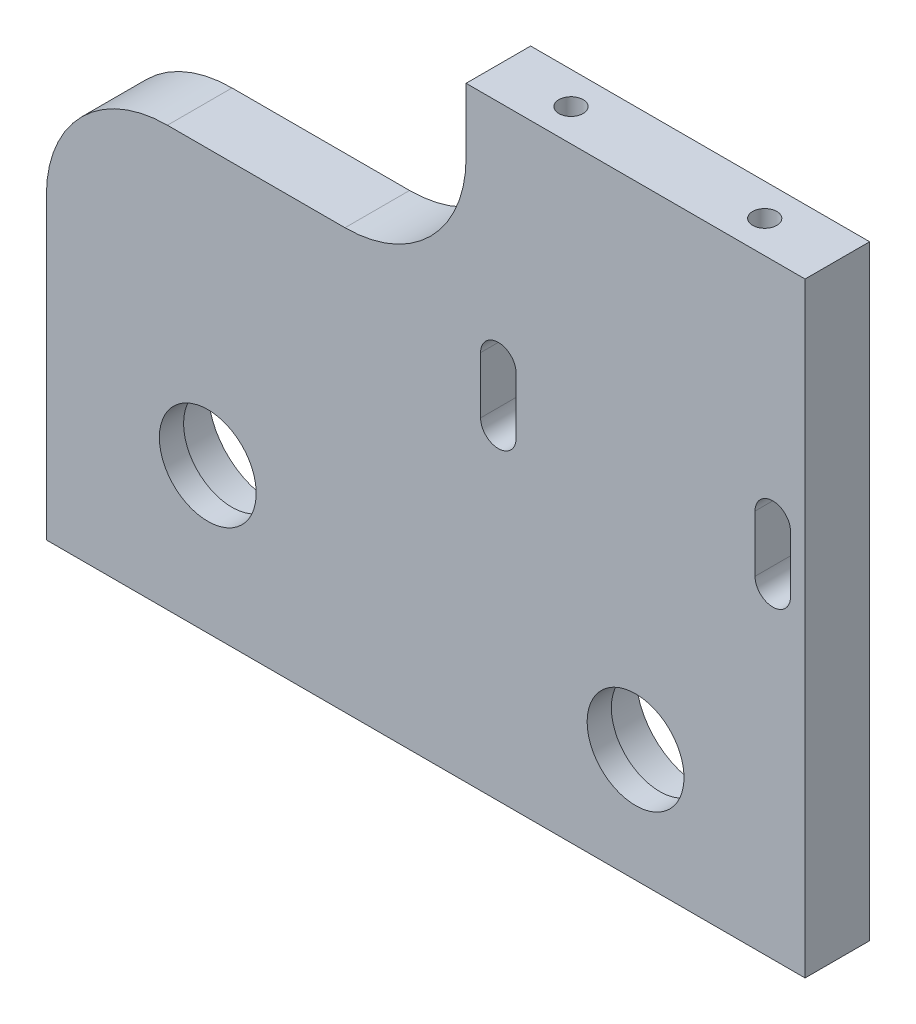
from build123d import *

# Parameters (mm, degrees)
BOSS_EXTRU_1_DEPTH      = 8
ESQUISSE2_R             = 7.95
ENL_V_MAT_EXTRU_1_DEPTH = 5
ESQUISSE3_R             = 6
ENL_V_MAT_EXTRU_2_DEPTH = 4
ENL_V_MAT_EXTRU_3_DEPTH = 9
ESQUISSE5_R             = 1.5
ENL_V_MAT_EXTRU_4_DEPTH = 30
CONG_1_R                = 15
ESQUISSE6_R             = 1.5
ENL_V_MAT_EXTRU_5_DEPTH = 20


with BuildPart() as part:
    # Esquisse1 → Boss.-Extru.1 (new body)
    with BuildSketch(Plane.XY):
        Polygon((52, 75), (52, 52), (0, 52), (0, 0), (94, 0), (94, 75), align=None)
    extrude(amount=BOSS_EXTRU_1_DEPTH)

    # Esquisse2 → Enlèv. mat.-Extru.1 (cut)
    with BuildSketch(Plane(origin=(0, 0, 0), x_dir=(-1, 0, 0), z_dir=(0, 0, -1))):
        with Locations((-20, 18)):
            Circle(ESQUISSE2_R)
        with Locations((-73, 14)):
            Circle(ESQUISSE2_R)
    extrude(amount=-ENL_V_MAT_EXTRU_1_DEPTH, mode=Mode.SUBTRACT)

    # Esquisse3 → Enlèv. mat.-Extru.2 (cut, through all)
    with BuildSketch(Plane(origin=(0, 0, 5), x_dir=(-1, 0, 0), z_dir=(0, 0, -1))):
        with Locations((-73, 14)):
            Circle(ESQUISSE3_R)
        with Locations((-20, 18)):
            Circle(ESQUISSE3_R)
    extrude(amount=-ENL_V_MAT_EXTRU_2_DEPTH, mode=Mode.SUBTRACT)

    # Esquisse4 → Enlèv. mat.-Extru.3 (cut, through all)
    with BuildSketch(Plane(origin=(0, 0, 0), x_dir=(-1, 0, 0), z_dir=(0, 0, -1))):
        with BuildLine():
            Line((-92.2, 40), (-92.2, 47))
            ThreePointArc((-92.2, 47), (-90, 49.2), (-87.8, 47))
            Line((-87.8, 47), (-87.8, 40))
            ThreePointArc((-87.8, 40), (-90, 37.8), (-92.2, 40))
        make_face()
        with BuildLine():
            Line((-53.8, 40), (-53.8, 47))
            ThreePointArc((-53.8, 47), (-56, 49.2), (-58.2, 47))
            Line((-58.2, 47), (-58.2, 40))
            ThreePointArc((-58.2, 40), (-56, 37.8), (-53.8, 40))
        make_face()
    extrude(amount=-ENL_V_MAT_EXTRU_3_DEPTH, mode=Mode.SUBTRACT)

    # Esquisse5 → Enlèv. mat.-Extru.4 (cut)
    with BuildSketch(Plane(origin=(0, 75, 0), x_dir=(1, 0, 0), z_dir=(0, 1, 0))):
        with Locations((61, -4)):
            Circle(ESQUISSE5_R)
        with Locations((85, -4)):
            Circle(ESQUISSE5_R)
    extrude(amount=-ENL_V_MAT_EXTRU_4_DEPTH, mode=Mode.SUBTRACT)

    # Congé1
    cong_1_edges = [part.edges().sort_by_distance(p)[0] for p in [
        (0, 52, 4),
        (52, 52, 4),
    ]]
    fillet(cong_1_edges, radius=CONG_1_R)

    # Esquisse6 → Enlèv. mat.-Extru.5 (cut)
    with BuildSketch(Plane.XZ):
        with Locations((6, 4)):
            Circle(ESQUISSE6_R)
        with Locations((88, 4)):
            Circle(ESQUISSE6_R)
    extrude(amount=-ENL_V_MAT_EXTRU_5_DEPTH, mode=Mode.SUBTRACT)


solid = part.part
